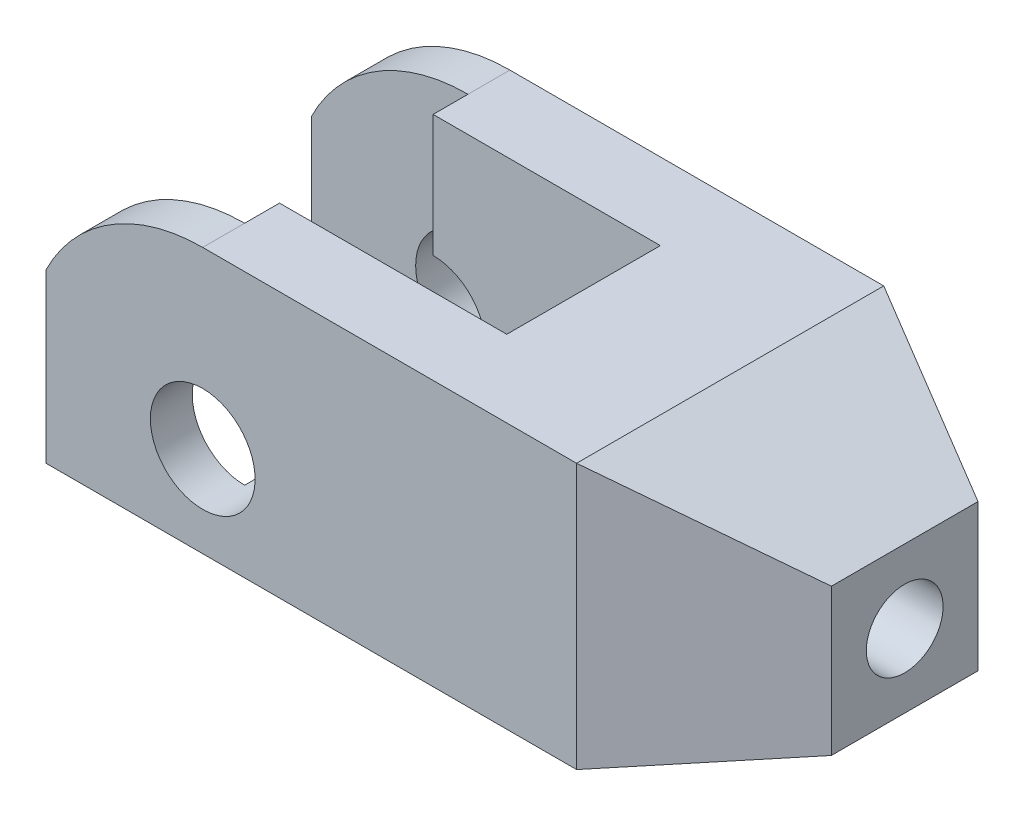
from build123d import *

# Parameters (mm, degrees)
SKETCH1_W               = 76
SKETCH1_H               = 44
BOSS_EXTRUDE1_DEPTH     = 38
SKETCH2_R               = 7.5
CUT_EXTRUDE1_DEPTH      = 1
CUT_EXTRUDE1_DEPTH_BACK = 45
SKETCH3_W               = 22.449944321
SKETCH3_H               = 32
SKETCH3_W_2             = 32.550055679
SKETCH3_H_2             = 22
CUT_EXTRUDE2_DEPTH      = 1
CUT_EXTRUDE2_DEPTH_BACK = 39
SKETCH5_W               = 44
SKETCH5_H               = 38
SKETCH4_W               = 21
SKETCH4_H               = 21
SKETCH6_R               = 5.5
CUT_EXTRUDE3_DEPTH      = 1.0000001
CUT_EXTRUDE3_DEPTH_BACK = 102


with BuildPart() as part:
    # Sketch1 → Boss-Extrude1 (new body)
    with BuildSketch(Plane(origin=(0, 0, 0), x_dir=(1, 0, 0), z_dir=(0, 1, 0))):
        Rectangle(SKETCH1_W, SKETCH1_H)
    extrude(amount=BOSS_EXTRUDE1_DEPTH)

    # Sketch2 → Cut-Extrude1 (cut, two sides)
    with BuildSketch(Plane.XY.offset(22)) as cut_extrude1_sk:
        with Locations((-15.550055679, 13)):
            Circle(SKETCH2_R)
        with BuildLine():
            Line((-15.550055679, 38), (-38, 38))
            Line((-38, 38), (-38, 24))
            ThreePointArc((-38, 24), (-28.778812235, 34.213203436), (-15.550055679, 38))
        make_face()
    extrude(amount=CUT_EXTRUDE1_DEPTH, mode=Mode.SUBTRACT)
    extrude(cut_extrude1_sk.sketch, amount=-CUT_EXTRUDE1_DEPTH_BACK, mode=Mode.SUBTRACT)

    # Sketch3 → Cut-Extrude2 (cut, two sides)
    with BuildSketch(Plane(origin=(0, 38, 0), x_dir=(1, 0, 0), z_dir=(0, 1, 0))) as cut_extrude2_sk:
        with Locations((-26.77502784, 0)):
            Rectangle(SKETCH3_W, SKETCH3_H)
        with Locations((0.72497216, 0)):
            Rectangle(SKETCH3_W_2, SKETCH3_H_2)
    extrude(amount=CUT_EXTRUDE2_DEPTH, mode=Mode.SUBTRACT)
    extrude(cut_extrude2_sk.sketch, amount=-CUT_EXTRUDE2_DEPTH_BACK, mode=Mode.SUBTRACT)

    # Sketch5 → Loft1 section 0
    with BuildSketch(Plane(origin=(38, 0, 0), x_dir=(0, 0, -1), z_dir=(1, 0, 0))):
        with Locations((0, 19)):
            Rectangle(SKETCH5_W, SKETCH5_H)
    # Sketch4 → Loft1 section 1
    with BuildSketch(Plane(origin=(63, 0, 0), x_dir=(0, 0, -1), z_dir=(1, 0, 0))):
        with Locations((0, 19)):
            Rectangle(SKETCH4_W, SKETCH4_H)
    loft()

    # Sketch6 → Cut-Extrude3 (cut, two sides)
    with BuildSketch(Plane(origin=(63, 0, 0), x_dir=(0, 0, -1), z_dir=(1, 0, 0))) as cut_extrude3_sk:
        with Locations((0, 19)):
            Circle(SKETCH6_R)
    extrude(amount=CUT_EXTRUDE3_DEPTH, mode=Mode.SUBTRACT)
    extrude(cut_extrude3_sk.sketch, amount=-CUT_EXTRUDE3_DEPTH_BACK, mode=Mode.SUBTRACT)


solid = part.part
